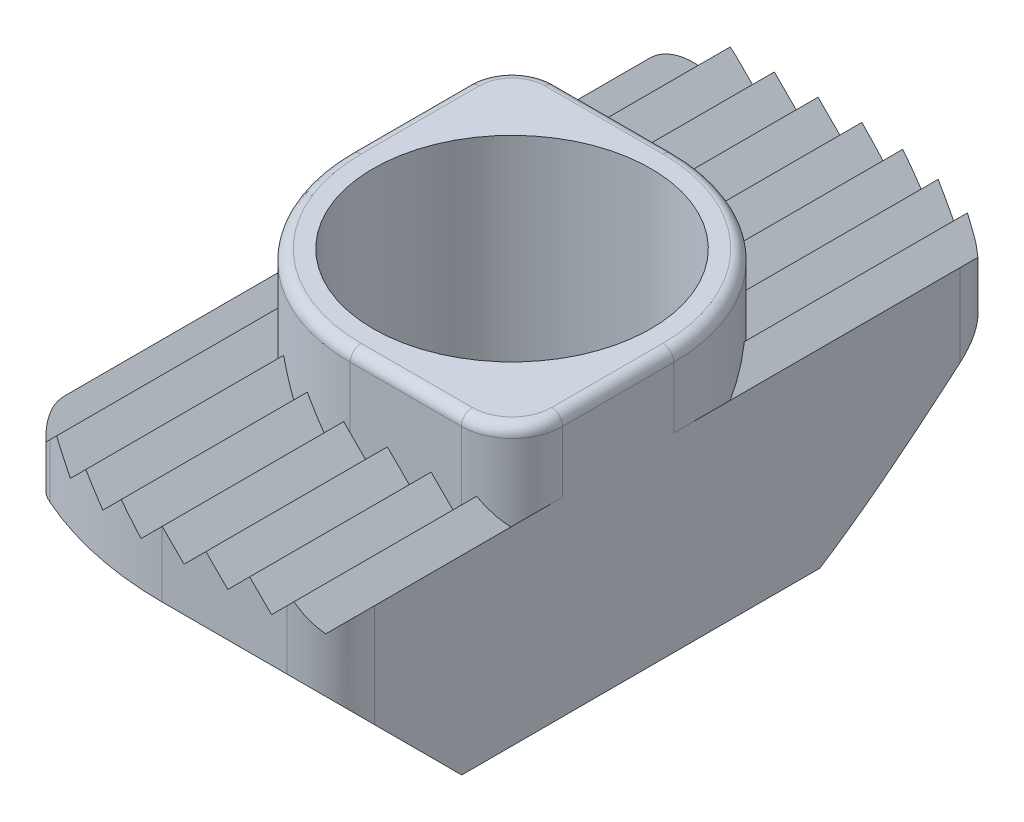
from build123d import *

# Parameters (mm, degrees)
EXTRUDE1_DEPTH          = 4.5
CUT_EXTRUDE1_DEPTH      = 8
CUT_EXTRUDE1_DEPTH_BACK = 8
EXTRUDE2_DEPTH          = 6.00039994
CUT_EXTRUDE2_DEPTH      = 4
CUT_EXTRUDE2_DEPTH_BACK = 4
CUT_REVOLVE1_ANGLE      = 60
CUT_REVOLVE2_ANGLE      = 60
SKETCH9_R               = 2.48793
CUT_EXTRUDE3_DEPTH      = 7.00040004
FILLET4_R               = 0.25
SKETCH10_R              = 2.48793
EXTRUDE3_DEPTH          = 6.0004
SKETCH12_R              = 3.175
CUT_EXTRUDE4_DEPTH      = 7.00040004


with BuildPart() as part:
    # Sketch1 → Extrude1 (new body)
    with BuildSketch(Plane(origin=(0, 0, 0), x_dir=(1, 0, 0), z_dir=(0, 1, 0))):
        with BuildLine():
            Line((0, -8), (2.85, -8))
            ThreePointArc((2.85, -8), (3.557106781, -7.707106781), (3.85, -7))
            Line((3.85, -7), (3.85, 6.393551439))
            ThreePointArc((3.85, 6.393551439), (3.688791661, 6.938003962), (3.2571429, 7.306915911))
            ThreePointArc((3.2571429, 7.306915911), (1.66503344, 7.824810774), (0, 8))
            Line((0, 8), (-2.85, 8))
            ThreePointArc((-2.85, 8), (-3.557106781, 7.707106781), (-3.85, 7))
            Line((-3.85, 7), (-3.85, -6.393551439))
            ThreePointArc((-3.85, -6.393551439), (-3.688791661, -6.938003962), (-3.2571429, -7.306915911))
            ThreePointArc((-3.2571429, -7.306915911), (-1.66503344, -7.824810774), (0, -8))
        make_face()
    extrude(amount=EXTRUDE1_DEPTH)

    # Sketch2 → Cut-Extrude1 (cut, two sides)
    with BuildSketch(Plane.XY) as cut_extrude1_sk:
        Polygon((-4, 4.5), (-3.5, 4), (-3, 4.5), (-2.5, 4), (-2, 4.5), (-1.5, 4), (-1, 4.5), (-0.5, 4), (0, 4.5), (0.5, 4), (1, 4.5), (1.5, 4), (2, 4.5), (2.5, 4), (3, 4.5), (3.5, 4), (4, 4.5), (4, 5.5), (-4, 5.5), align=None)
    extrude(amount=CUT_EXTRUDE1_DEPTH, mode=Mode.SUBTRACT)
    extrude(cut_extrude1_sk.sketch, amount=-CUT_EXTRUDE1_DEPTH_BACK, mode=Mode.SUBTRACT)

    # Sketch3 → Extrude2 (add)
    with BuildSketch(Plane(origin=(0, 0, 0), x_dir=(1, 0, 0), z_dir=(0, 1, 0))):
        with BuildLine():
            Line((0.15, -3.85), (2.693303618, -3.85))
            ThreePointArc((2.693303618, -3.85), (3.511211473, -3.511211473), (3.85, -2.693303618))
            Line((3.85, -2.693303618), (3.85, -0.15))
            ThreePointArc((3.85, -0.15), (2.678427125, 2.678427125), (-0.15, 3.85))
            Line((-0.15, 3.85), (-2.85, 3.85))
            ThreePointArc((-2.85, 3.85), (-3.557106781, 3.557106781), (-3.85, 2.85))
            Line((-3.85, 2.85), (-3.85, 0.15))
            ThreePointArc((-3.85, 0.15), (-2.678427125, -2.678427125), (0.15, -3.85))
        make_face()
    extrude(amount=EXTRUDE2_DEPTH)

    # Sketch4 → Cut-Extrude2 (cut, two sides)
    with BuildSketch(Plane(origin=(0, 0, 0), x_dir=(0, 0, -1), z_dir=(1, 0, 0))) as cut_extrude2_sk:
        Polygon((-9, -1), (9, -1), (9, 4), (5, 0), (-5, 0), (-9, 4), align=None)
    extrude(amount=CUT_EXTRUDE2_DEPTH, mode=Mode.SUBTRACT)
    extrude(cut_extrude2_sk.sketch, amount=-CUT_EXTRUDE2_DEPTH_BACK, mode=Mode.SUBTRACT)

    # Sketch5 → Cut-Revolve1 (revolve, cut)
    with BuildSketch(Plane(origin=(0, 0, 0), x_dir=(0, 0, -1), z_dir=(1, 0, 0))):
        Polygon((0, -1), (-9, -1), (-9, 3), (-8, 3), (-5, 0), (0, 0), align=None)
    revolve(axis=Axis((0, 3, 0), (0, -1, 0)), revolution_arc=CUT_REVOLVE1_ANGLE, mode=Mode.SUBTRACT)

    # Sketch6 → Cut-Revolve2 (revolve, cut)
    with BuildSketch(Plane(origin=(0, 0, 0), x_dir=(0, 0, -1), z_dir=(1, 0, 0))):
        Polygon((0, 0), (5, 0), (8, 3), (9, 3), (9, -1), (0, -1), align=None)
    revolve(axis=Axis((0, -1, 0), (0, -1, 0)), revolution_arc=CUT_REVOLVE2_ANGLE, mode=Mode.SUBTRACT)

    # Sketch9 → Cut-Extrude3 (cut, through all)
    with BuildSketch(Plane(origin=(0, 6.00039994, 0), x_dir=(1, 0, 0), z_dir=(0, 1, 0))):
        Circle(SKETCH9_R)
    extrude(amount=-CUT_EXTRUDE3_DEPTH, mode=Mode.SUBTRACT)

    # Fillet4
    fillet4_edges = [part.edges().sort_by_distance(p)[0] for p in [
        (-2.678427125, 6.00039994, 2.678427125),
        (1.421651809, 6.00039994, 3.85),
        (3.511211473, 6.00039994, 3.511211473),
        (3.85, 6.00039994, 1.421651809),
        (2.678427125, 6.00039994, -2.678427125),
        (-1.5, 6.00039994, -3.85),
        (-3.557106781, 6.00039994, -3.557106781),
        (-3.85, 6.00039994, -1.5),
    ]]
    fillet(fillet4_edges, radius=FILLET4_R)

    # Sketch10 → Extrude3 (add)
    with BuildSketch(Plane(origin=(0, 6.00039994, 0), x_dir=(1, 0, 0), z_dir=(0, 1, 0))):
        Circle(SKETCH10_R)
    extrude(amount=-EXTRUDE3_DEPTH)

    # Sketch12 → Cut-Extrude4 (cut, through all)
    with BuildSketch(Plane(origin=(0, 6.00039994, 0), x_dir=(1, 0, 0), z_dir=(0, 1, 0))):
        Circle(SKETCH12_R)
    extrude(amount=-CUT_EXTRUDE4_DEPTH, mode=Mode.SUBTRACT)


solid = part.part
